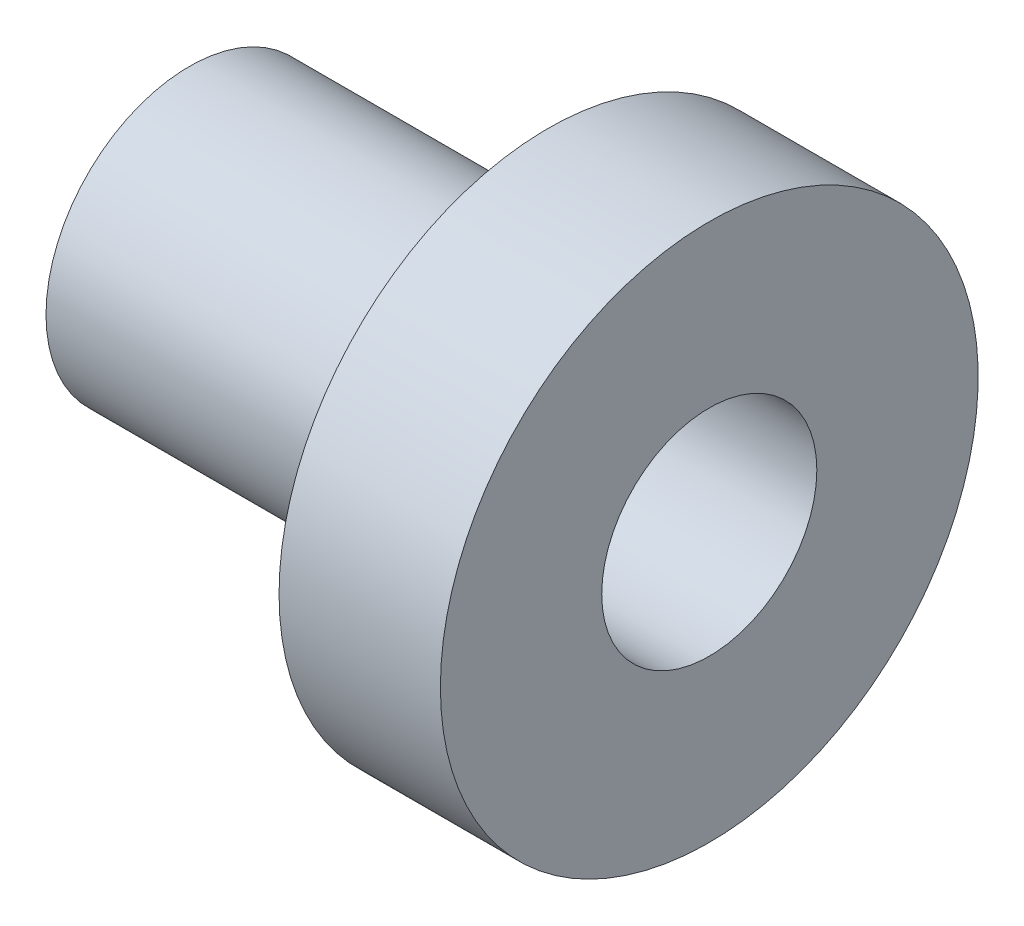
from build123d import *


with BuildPart() as part:
    # Esquisse1 → Révolution1 (revolve)
    with BuildSketch(Plane.XY):
        Polygon((-9, 15), (0, 15), (0, 6), (-29, 6), (-29, 8), (-9, 8), align=None)
    revolve(axis=Axis((-32.389049538, 0, 0), (1, 0, 0)))


solid = part.part
